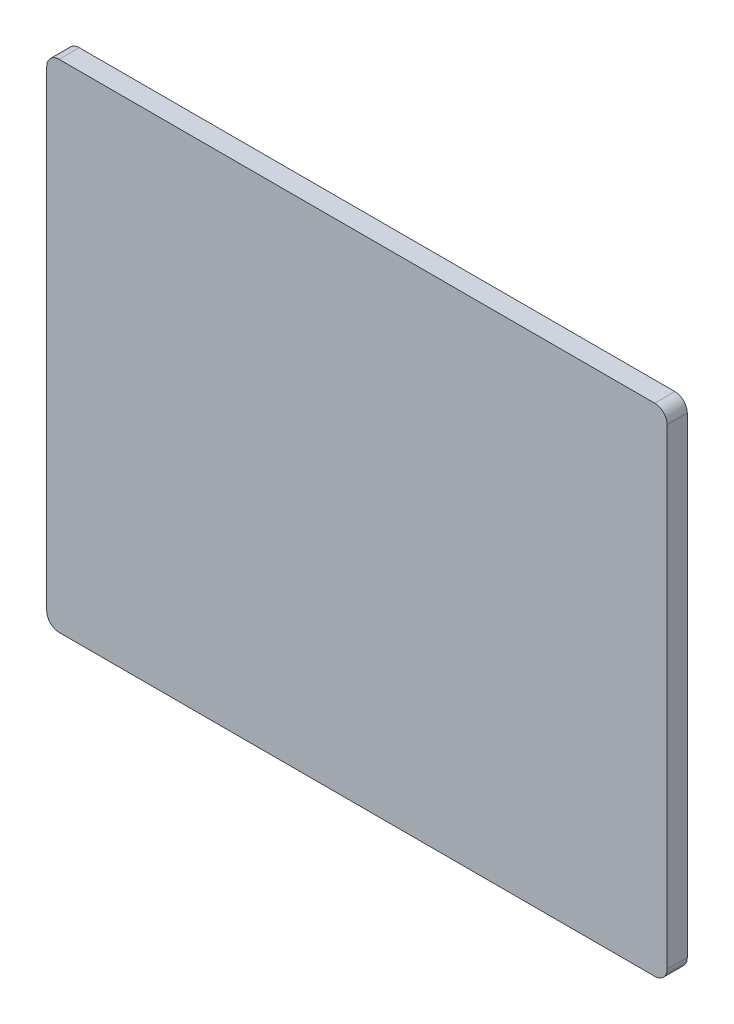
from build123d import *

# Parameters (mm, degrees)
SKETCH_1_W      = 400
SKETCH_1_H      = 320
EXTRUDE_1_DEPTH = 13
FILLET_1_R      = 8


with BuildPart() as part:
    # 스케치1 → 보스-돌출1 (new body)
    with BuildSketch(Plane.XY.offset(13)):
        with Locations((-2.722973759, -83.26756851)):
            Rectangle(SKETCH_1_W, SKETCH_1_H)
    extrude(amount=-EXTRUDE_1_DEPTH)

    # 필렛1
    fillet_1_edges = [part.edges().sort_by_distance(p)[0] for p in [
        (197.277026241, 76.73243149, 6.5),
        (197.277026241, -243.26756851, 6.5),
        (-202.722973759, -243.26756851, 6.5),
        (-202.722973759, 76.73243149, 6.5),
    ]]
    fillet(fillet_1_edges, radius=FILLET_1_R)


solid = part.part
